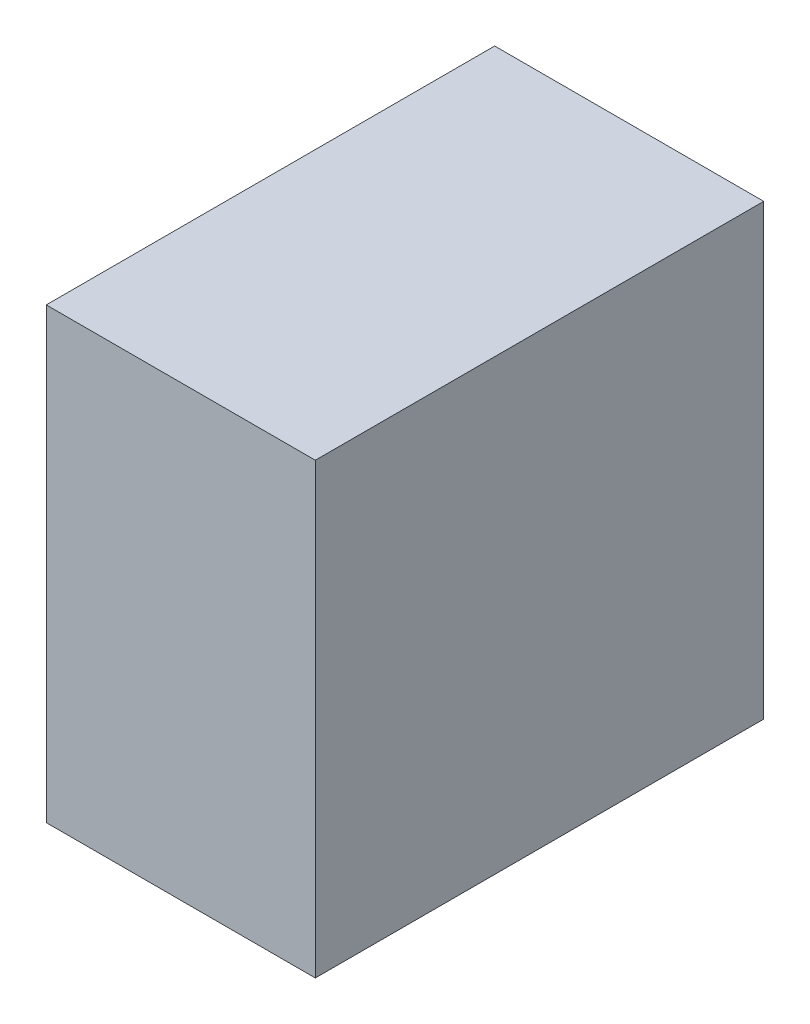
from build123d import *

# Parameters (mm, degrees)
SKETCH1_W           = 50
SKETCH1_H           = 50
BOSS_EXTRUDE1_DEPTH = 30


with BuildPart() as part:
    # Sketch1 → Boss-Extrude1 (new body)
    with BuildSketch(Plane(origin=(0, 0, 0), x_dir=(0, 0, -1), z_dir=(1, 0, 0))):
        Rectangle(SKETCH1_W, SKETCH1_H)
    extrude(amount=BOSS_EXTRUDE1_DEPTH)


solid = part.part
